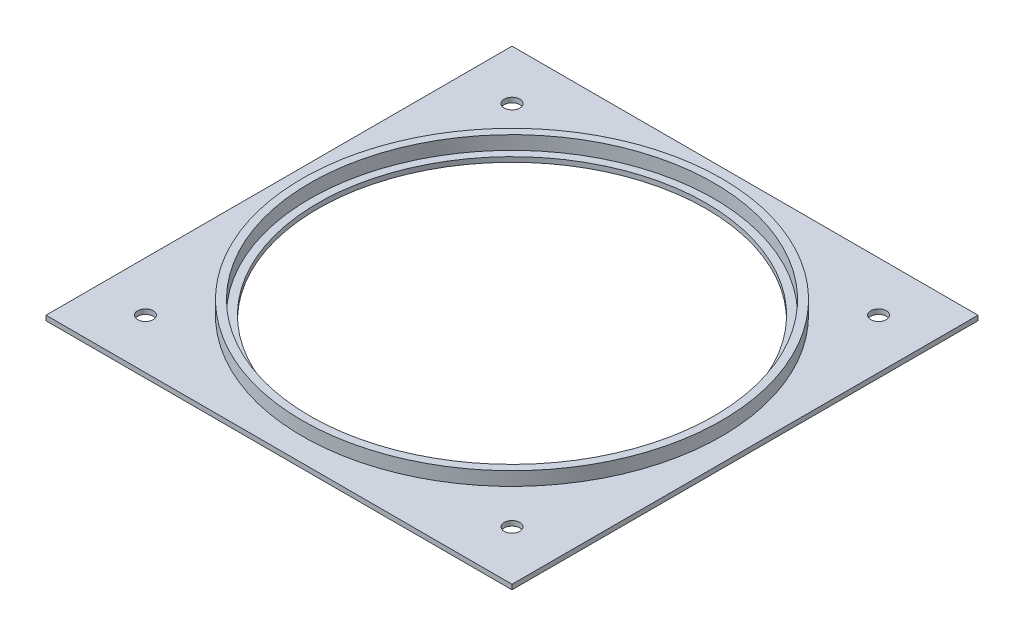
from build123d import *

# Parameters (mm, degrees)
SKETCH1_W           = 152.4
SKETCH1_H           = 152.4
SKETCH1_R           = 63.5
SKETCH1_R_2         = 2.54
BOSS_EXTRUDE1_DEPTH = 1.5875
SKETCH2_R           = 68.58
SKETCH2_R_2         = 66.04
BOSS_EXTRUDE2_DEPTH = 4.445


with BuildPart() as part:
    # Sketch1 → Boss-Extrude1 (new body)
    with BuildSketch(Plane(origin=(0, 0, 0), x_dir=(1, 0, 0), z_dir=(0, 1, 0))):
        Rectangle(SKETCH1_W, SKETCH1_H)
        Circle(SKETCH1_R, mode=Mode.SUBTRACT)
        with Locations((-59.944, 59.944)):
            Circle(SKETCH1_R_2, mode=Mode.SUBTRACT)
        with Locations((59.944, 59.944)):
            Circle(SKETCH1_R_2, mode=Mode.SUBTRACT)
        with Locations((59.944, -59.944)):
            Circle(SKETCH1_R_2, mode=Mode.SUBTRACT)
        with Locations((-59.944, -59.944)):
            Circle(SKETCH1_R_2, mode=Mode.SUBTRACT)
    extrude(amount=BOSS_EXTRUDE1_DEPTH)

    # Sketch2 → Boss-Extrude2 (add)
    with BuildSketch(Plane(origin=(0, 1.5875, 0), x_dir=(1, 0, 0), z_dir=(0, 1, 0))):
        Circle(SKETCH2_R)
        Circle(SKETCH2_R_2, mode=Mode.SUBTRACT)
    extrude(amount=BOSS_EXTRUDE2_DEPTH)


solid = part.part
